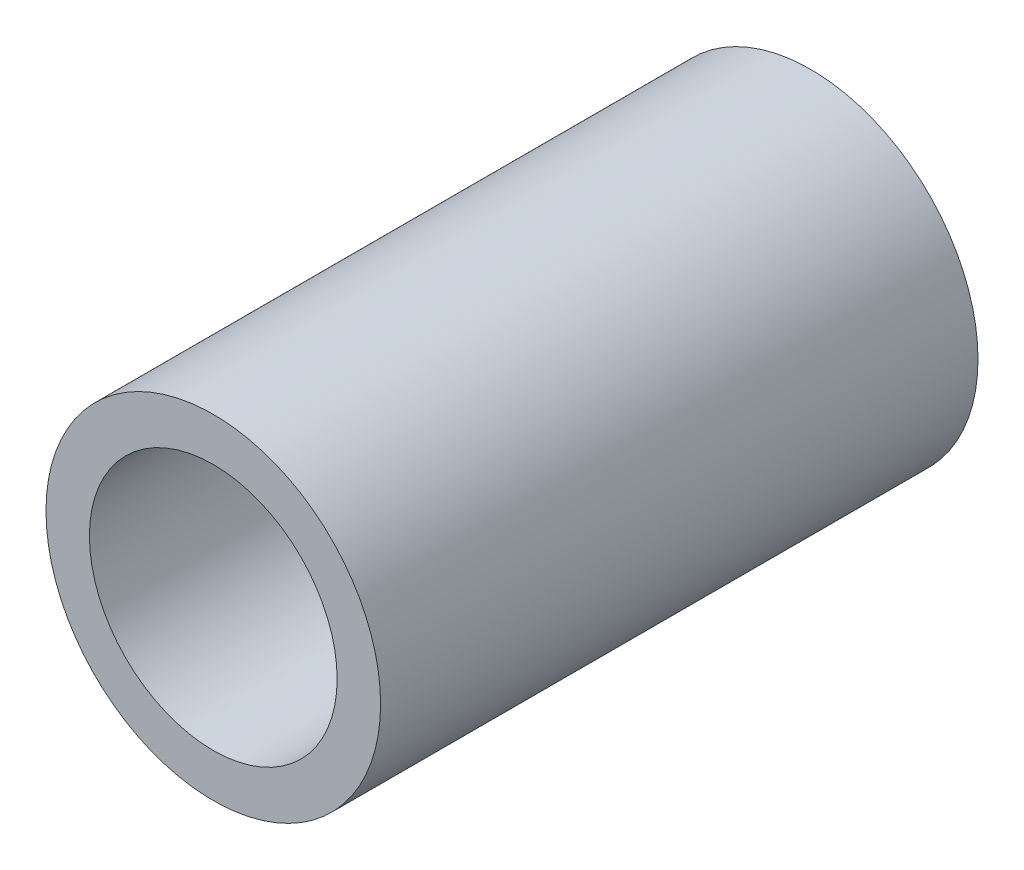
from build123d import *

# Parameters (mm, degrees)
SKETCH1_R           = 10.668
SKETCH1_R_2         = 7.8994
EXTRUDE_THIN1_DEPTH = 19.05


with BuildPart() as part:
    # Sketch1 → Extrude-Thin1 (new body, symmetric)
    with BuildSketch(Plane.XY):
        Circle(SKETCH1_R)
        Circle(SKETCH1_R_2, mode=Mode.SUBTRACT)
    extrude(amount=EXTRUDE_THIN1_DEPTH, both=True)


solid = part.part
